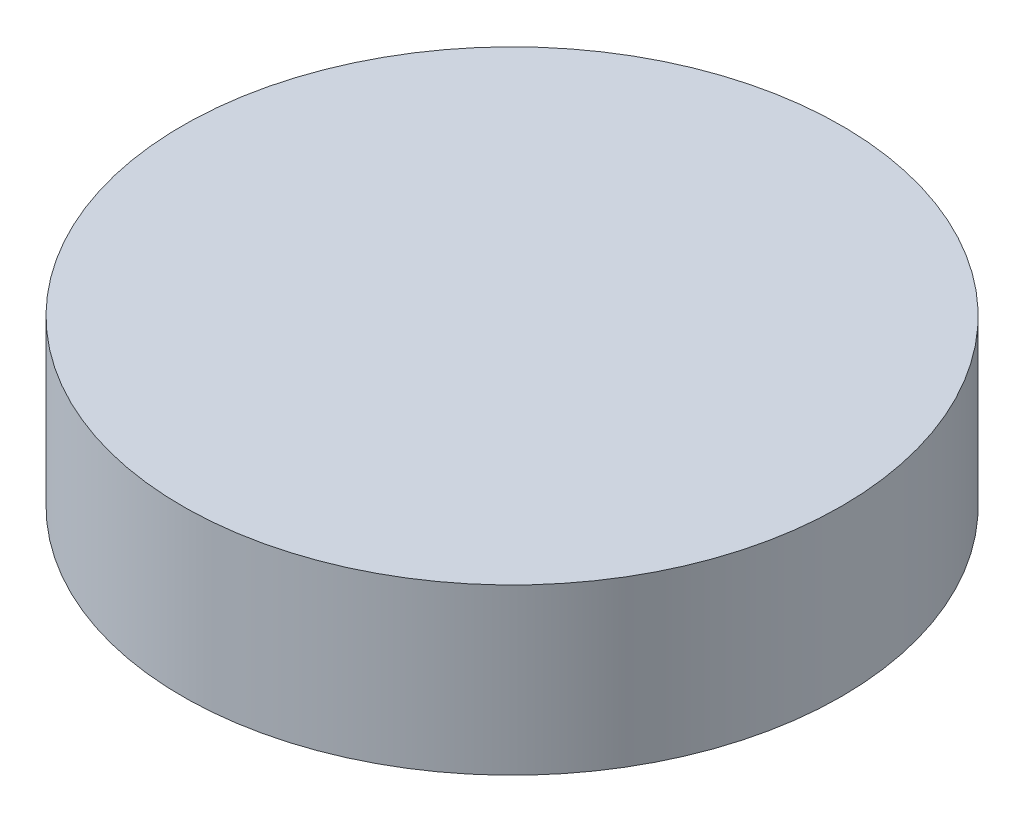
from build123d import *


with BuildPart() as part:
    # Sketch1 → Revolve1 (revolve)
    with BuildSketch(Plane.XY):
        with BuildLine():
            Line((-3.815756806, 0), (-12, 0))
            Line((-12, 0), (-12, 6))
            Line((-12, 6), (0, 6))
            Line((0, 6), (0, 5.2))
            ThreePointArc((0, 5.2), (-3.224903099, 3.566431913), (-3.815756806, 0))
        make_face()
    revolve(axis=Axis((0, 5.2, 0), (0, 1, 0)))


solid = part.part
